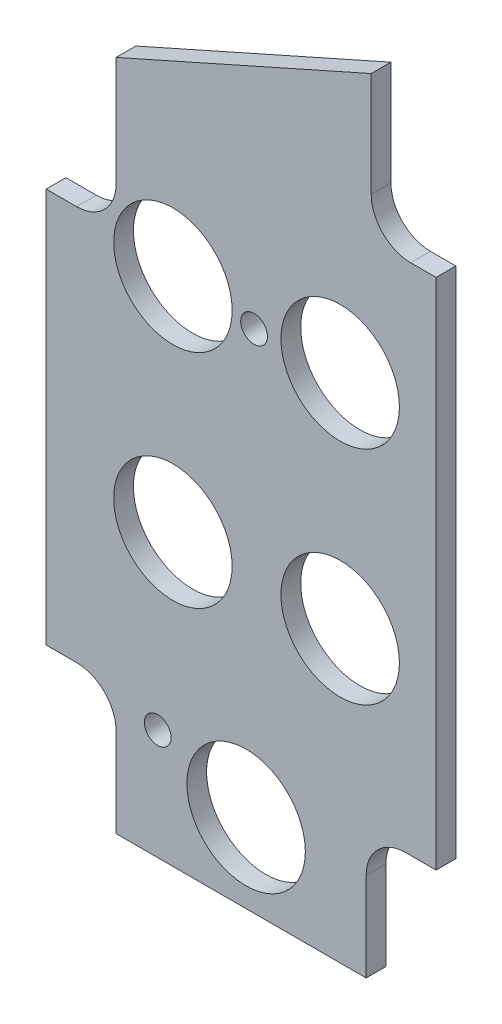
from build123d import *

# Parameters (mm, degrees)
BOSS_EXTRUDE1_DEPTH   = 3.175
SKETCH2_R             = 9.525
CUT_EXTRUDE1_DEPTH    = 4.175
F_6_CLEARANCE_HOLE1_D = 4.3053
CUT_EXTRUDE2_DEPTH    = 4.175
F_6_CLEARANCE_HOLE2_D = 4.3053


with BuildPart() as part:
    # Sketch1 → Boss-Extrude1 (new body)
    with BuildSketch(Plane.XY):
        Polygon((0, 103.090949096), (0, 0), (62.688793586, 0), (62.688793586, 131), align=None)
    extrude(amount=-BOSS_EXTRUDE1_DEPTH)

    # Sketch2 → Cut-Extrude1 (cut, through all)
    with BuildSketch(Plane.XY):
        with Locations((32.143907641, 12.7)):
            Circle(SKETCH2_R)
        with Locations((47.270490427, 46.548006151)):
            Circle(SKETCH2_R)
        with Locations((47.270490427, 82.18542385)):
            Circle(SKETCH2_R)
        with Locations((20.373235059, 82.18542385)):
            Circle(SKETCH2_R)
        with Locations((20.373235059, 46.548006151)):
            Circle(SKETCH2_R)
    extrude(amount=-CUT_EXTRUDE1_DEPTH, mode=Mode.SUBTRACT)

    # #6 Clearance Hole1 (through all)
    with Locations(Plane.XY):
        with Locations((58.6105, 14.2875), (4.8895, 14.2875), (4.8895, 90.4875), (58.6105, 109.5375)):
            Hole(F_6_CLEARANCE_HOLE1_D / 2)

    # Sketch5 → Cut-Extrude2 (cut, through all)
    with BuildSketch(Plane.XY):
        with BuildLine():
            Line((0, 0), (11.24, 0))
            Line((11.24, 0), (11.24, 14.29))
            ThreePointArc((11.24, 14.29), (9.380128061, 18.780128061), (4.89, 20.64))
            Line((4.89, 20.64), (0, 20.64))
            Line((0, 20.64), (0, 0))
        make_face()
        with BuildLine():
            Line((51.448793586, 14.29), (51.448793586, 0))
            Line((51.448793586, 0), (62.688793586, 0))
            Line((62.688793586, 0), (62.688793586, 20.64))
            Line((62.688793586, 20.64), (57.798793586, 20.64))
            ThreePointArc((57.798793586, 20.64), (53.308665525, 18.780128061), (51.448793586, 14.29))
        make_face()
        with BuildLine():
            Line((0, 103.090949096), (0, 84.1375))
            Line((0, 84.1375), (4.8895, 84.1375))
            ThreePointArc((4.8895, 84.1375), (9.379628061, 85.997371939), (11.2395, 90.4875))
            Line((11.2395, 90.4875), (11.2395, 108.094774496))
            Line((11.2395, 108.094774496), (0, 103.090949096))
        make_face()
        with BuildLine():
            Line((62.688793586, 131), (62.688793586, 103.1875))
            Line((62.688793586, 103.1875), (58.6105, 103.1875))
            ThreePointArc((58.6105, 103.1875), (54.120371939, 105.047371939), (52.2605, 109.5375))
            Line((52.2605, 109.5375), (52.2605, 126.357323696))
            Line((52.2605, 126.357323696), (62.688793586, 131))
        make_face()
    extrude(amount=-CUT_EXTRUDE2_DEPTH, mode=Mode.SUBTRACT)

    # #6 Clearance Hole2 (through all)
    with Locations(Plane(origin=(31.750004441, 0, 3.175), x_dir=(1, 0, 0), z_dir=(0, 0, 1))):
        with Locations((1.676331213, 81.383391323), (-13.818696068, 17.771227958)):
            Hole(F_6_CLEARANCE_HOLE2_D / 2)


solid = part.part
